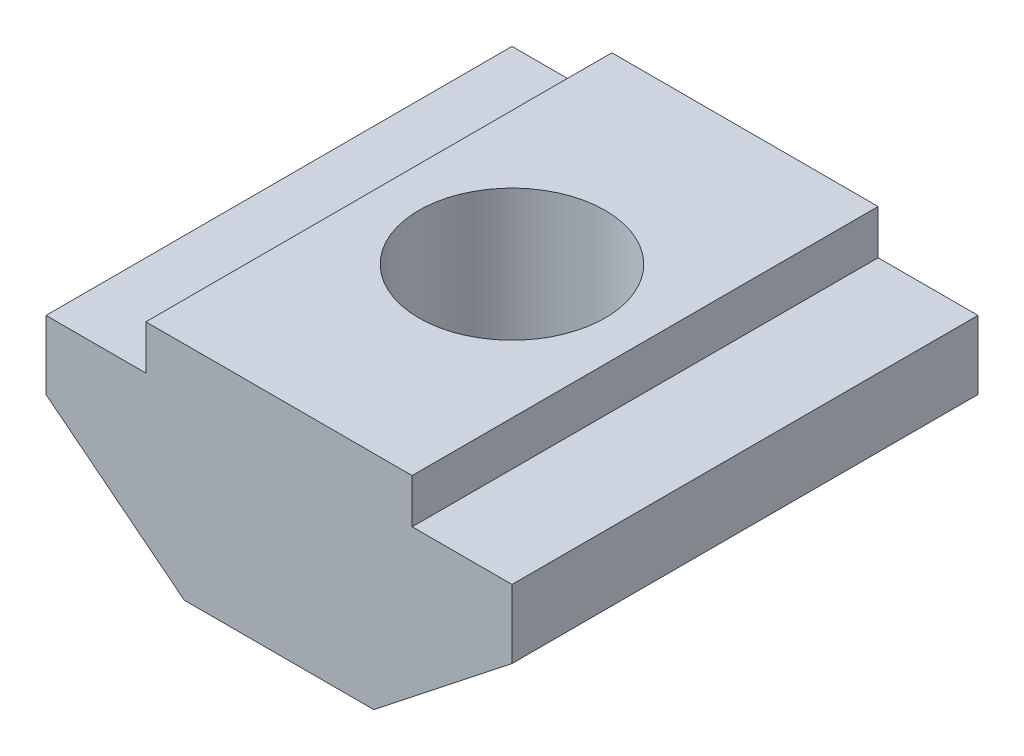
from build123d import *

# Parameters (mm, degrees)
BOSS_EXTRUDE1_DEPTH   = 10.5
M5X0_8_TAPPED_HOLE1_D = 4.2


with BuildPart() as part:
    # Sketch1 → Boss-Extrude1 (new body)
    with BuildSketch(Plane.XY):
        Polygon((-3, 5), (3, 5), (3, 4), (5.25, 4), (5.25, 2.455938691), (2.13559322, 0), (-2.13559322, 0), (-5.25, 2.455938691), (-5.25, 4), (-3, 4), align=None)
    extrude(amount=BOSS_EXTRUDE1_DEPTH)

    # M5x0.8 Tapped Hole1 (through all)
    with Locations(Plane(origin=(0, 5, 0), x_dir=(1, 0, 0), z_dir=(0, 1, 0))):
        with Locations((0, -5.25)):
            Hole(M5X0_8_TAPPED_HOLE1_D / 2)


solid = part.part
